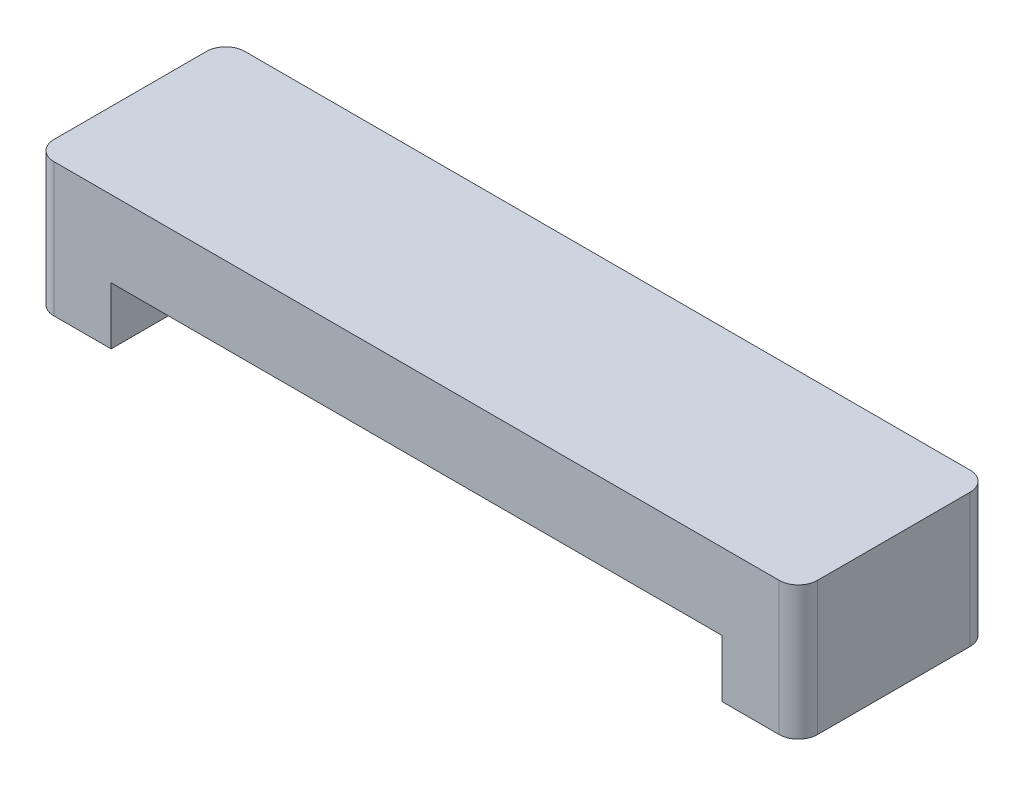
from build123d import *

# Parameters (mm, degrees)
IZIM1_W                     = 80
IZIM1_H                     = 14
Y_KSEKLIK_EKSTR_ZYON1_DEPTH = 20
KES_EKSTR_ZYON1_DEPTH       = 8
RADYUS1_R                   = 2


with BuildPart() as part:
    # Çizim1 → Yükseklik-Ekstrüzyon1 (new body)
    with BuildSketch(Plane.XY):
        with Locations((-11.444268973, 48.50560342)):
            Rectangle(IZIM1_W, IZIM1_H)
    extrude(amount=Y_KSEKLIK_EKSTR_ZYON1_DEPTH)

    # Çizim2 → Kes-Ekstrüzyon1 (cut)
    with BuildSketch(Plane.XY.offset(20)):
        Polygon((-11.444268973, 41.50560342), (-43.444268973, 41.50560342), (-43.444268973, 47.50560342), (20.555731027, 47.50560342), (20.555731027, 41.50560342), align=None)
    extrude(amount=-KES_EKSTR_ZYON1_DEPTH, mode=Mode.SUBTRACT)

    # Radyus1
    radyus1_edges = [part.edges().sort_by_distance(p)[0] for p in [
        (28.555731027, 48.50560342, 20),
        (-51.444268973, 48.50560342, 20),
        (28.555731027, 48.50560342, 0),
        (-51.444268973, 48.50560342, 0),
    ]]
    fillet(radyus1_edges, radius=RADYUS1_R)


solid = part.part
